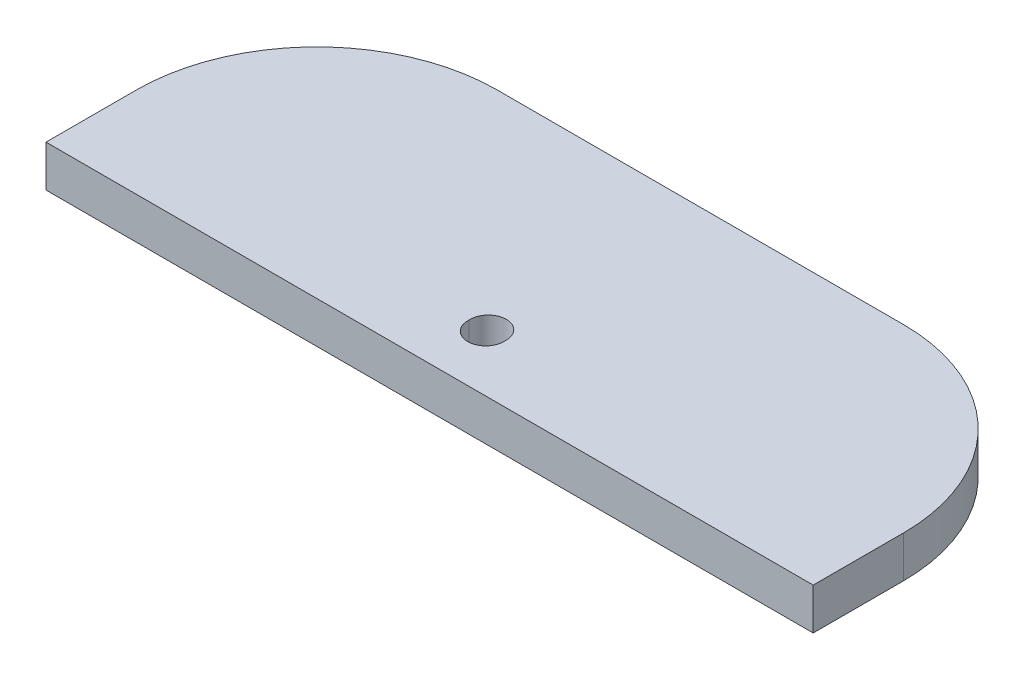
from build123d import *

# Parameters (mm, degrees)
SKETCH2_W           = 42.5
SKETCH2_H           = 15
SKETCH2_R           = 1
BOSS_EXTRUDE1_DEPTH = 2.3
FILLET9_R           = 10
SKETCH3_R           = 1
CUT_EXTRUDE1_DEPTH  = 3.3


with BuildPart() as part:
    # Sketch2 → Boss-Extrude1 (new body)
    with BuildSketch(Plane(origin=(0, 0, 0), x_dir=(1, 0, 0), z_dir=(0, 1, 0))):
        Rectangle(SKETCH2_W, SKETCH2_H)
        with Locations((0, -4.25)):
            Circle(SKETCH2_R, mode=Mode.SUBTRACT)
    extrude(amount=BOSS_EXTRUDE1_DEPTH)

    # Fillet9
    fillet9_edges = [part.edges().sort_by_distance(p)[0] for p in [
        (-21.25, 1.15, -7.5),
        (21.25, 1.15, -7.5),
    ]]
    fillet(fillet9_edges, radius=FILLET9_R)

    # Sketch3 → Cut-Extrude1 (cut, through all)
    with BuildSketch(Plane(origin=(0, 2.3, 0), x_dir=(1, 0, 0), z_dir=(0, 1, 0))):
        with Locations((0, -4.388678083)):
            Circle(SKETCH3_R)
    extrude(amount=-CUT_EXTRUDE1_DEPTH, mode=Mode.SUBTRACT)


solid = part.part
